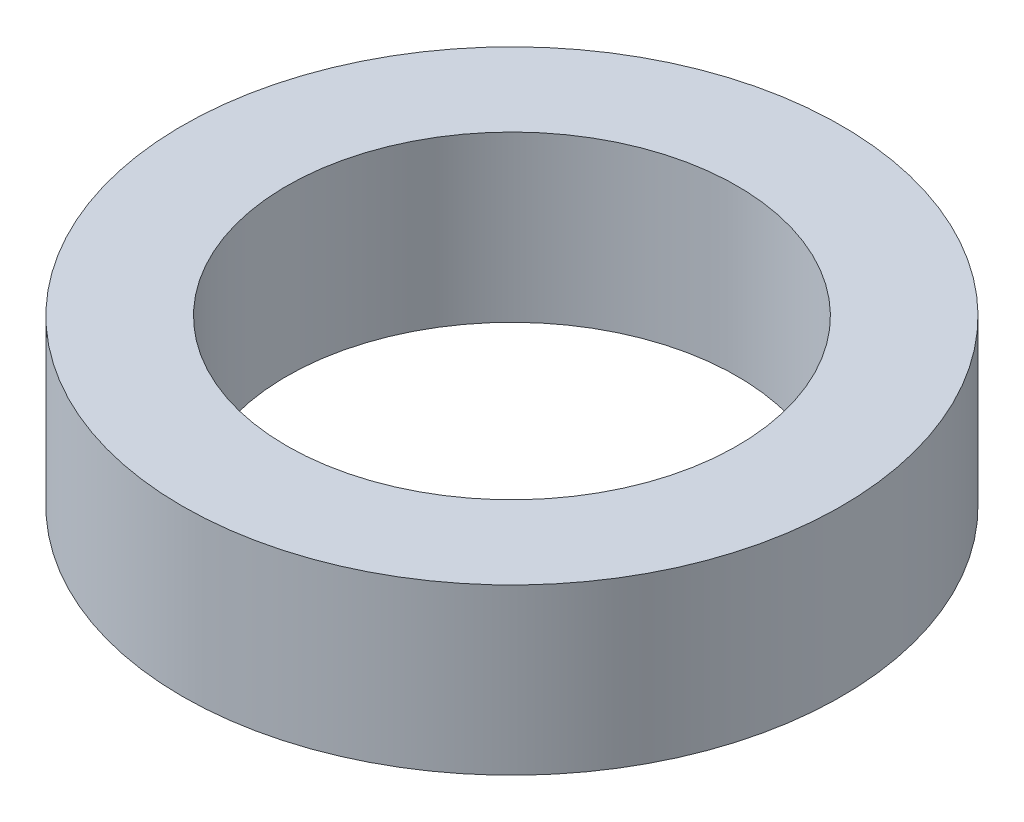
from build123d import *

# Parameters (mm, degrees)
SKETCH1_R           = 6
SKETCH1_R_2         = 4.1
BOSS_EXTRUDE1_DEPTH = 3


with BuildPart() as part:
    # Sketch1 → Boss-Extrude1 (new body)
    with BuildSketch(Plane(origin=(0, 0, 0), x_dir=(1, 0, 0), z_dir=(0, 1, 0))):
        Circle(SKETCH1_R)
        Circle(SKETCH1_R_2, mode=Mode.SUBTRACT)
    extrude(amount=BOSS_EXTRUDE1_DEPTH)


solid = part.part
